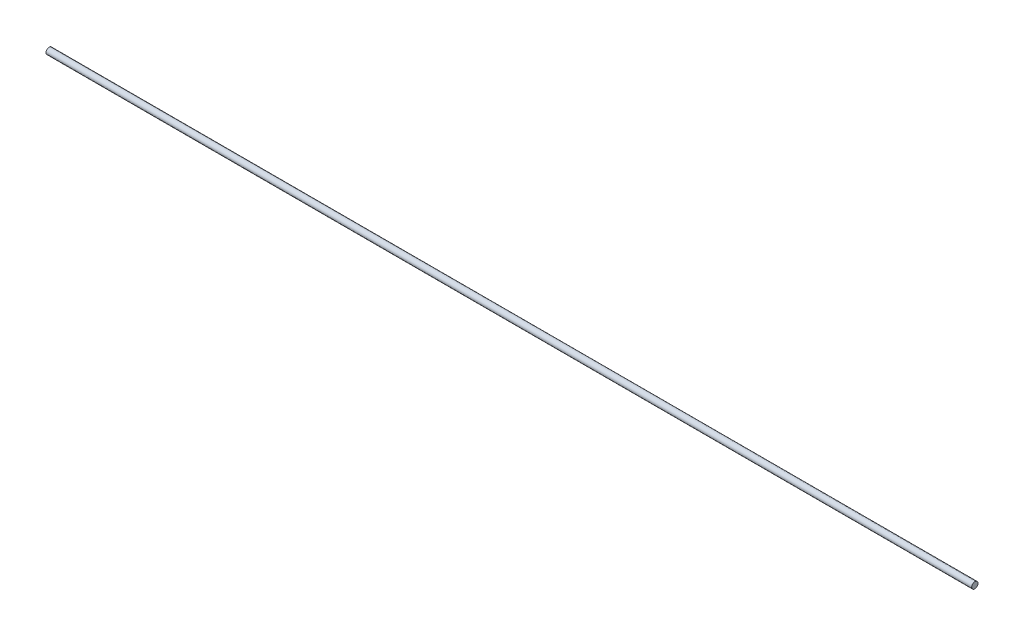
from build123d import *

# Parameters (mm, degrees)
SKETCH1_R           = 1
BOSS_EXTRUDE1_DEPTH = 295


with BuildPart() as part:
    # Sketch1 → Boss-Extrude1 (new body)
    with BuildSketch(Plane(origin=(0, 0, 0), x_dir=(0, 0, -1), z_dir=(1, 0, 0))):
        Circle(SKETCH1_R)
    extrude(amount=BOSS_EXTRUDE1_DEPTH)


solid = part.part
